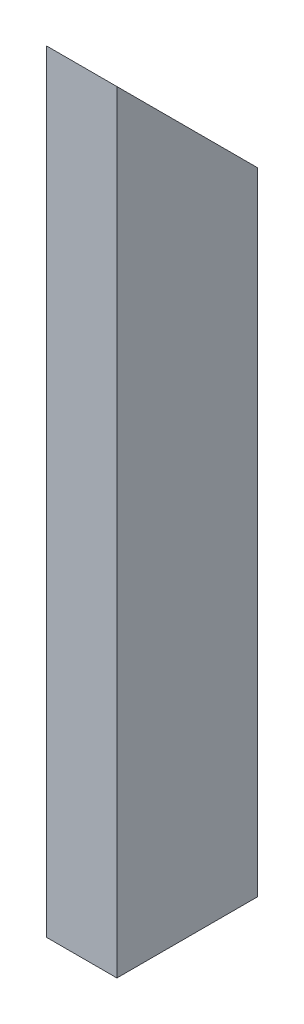
from build123d import *

# Parameters (mm, degrees)
SKETCH1_W           = 25.4
SKETCH1_H           = 50.8
SKETCH1_W_2         = 19.05
SKETCH1_H_2         = 44.45
BOSS_EXTRUDE1_DEPTH = 279.4
CUT_EXTRUDE1_DEPTH  = 279.4


with BuildPart() as part:
    # Sketch1 → Boss-Extrude1 (new body)
    with BuildSketch(Plane(origin=(0, 0, 0), x_dir=(1, 0, 0), z_dir=(0, 1, 0))):
        with Locations((12.7, 25.4)):
            Rectangle(SKETCH1_W, SKETCH1_H)
        with Locations((12.7, 25.4)):
            Rectangle(SKETCH1_W_2, SKETCH1_H_2, mode=Mode.SUBTRACT)
    extrude(amount=BOSS_EXTRUDE1_DEPTH)

    # Sketch2 → Cut-Extrude1 (cut)
    with BuildSketch(Plane(origin=(25.4, 0, 0), x_dir=(0, 0, -1), z_dir=(1, 0, 0))):
        Polygon((0, 279.4), (50.8, 228.6), (50.8, 279.4), align=None)
    extrude(amount=-CUT_EXTRUDE1_DEPTH, mode=Mode.SUBTRACT)


solid = part.part
